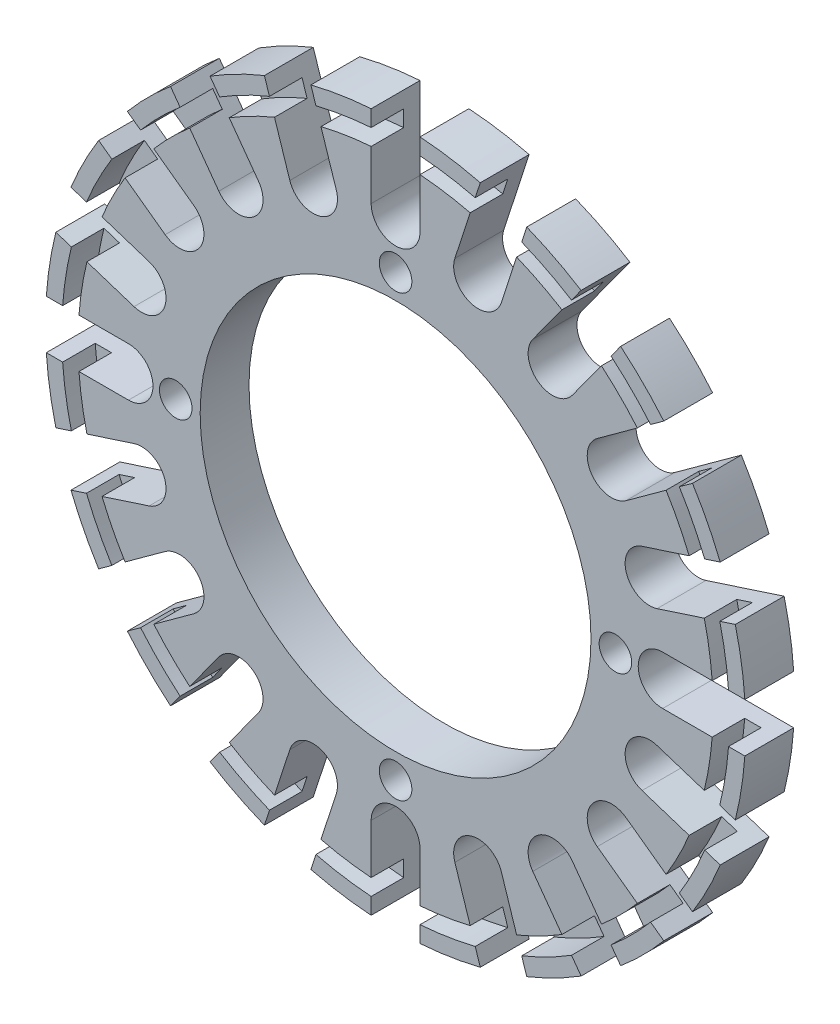
from build123d import *

# Parameters (mm, degrees)
SKETCH1_R           = 12
SKETCH1_R_2         = 1
BOSS_EXTRUDE1_DEPTH = 3
SKETCH2_R           = 20.5
SKETCH2_R_2         = 19.5
CUT_EXTRUDE1_DEPTH  = 2


with BuildPart() as part:
    # Sketch1 → Boss-Extrude1 (new body)
    with BuildSketch(Plane.XY):
        with BuildLine():
            Line((-1.5, 16.4), (-1.5, 21.44761059))
            ThreePointArc((-1.5, 21.44761059), (-3.363340998, 21.235299323), (-5.201091386, 20.861415302))
            Line((-5.201091386, 20.861415302), (-3.641293933, 16.060852359))
            ThreePointArc((-3.641293933, 16.060852359), (-4.604353216, 14.170742093), (-6.494463482, 15.133801376))
            Line((-6.494463482, 15.133801376), (-8.054260935, 19.934364319))
            ThreePointArc((-8.054260935, 19.934364319), (-9.760795744, 19.15664027), (-11.39306371, 18.233159334))
            Line((-11.39306371, 18.233159334), (-8.426152646, 14.149556586))
            ThreePointArc((-8.426152646, 14.149556586), (-8.758000259, 12.054353216), (-10.853203629, 12.386200829))
            Line((-10.853203629, 12.386200829), (-13.820114693, 16.469803577))
            ThreePointArc((-13.820114693, 16.469803577), (-15.202795796, 15.202795796), (-16.469803577, 13.820114693))
            Line((-16.469803577, 13.820114693), (-12.386200829, 10.853203629))
            ThreePointArc((-12.386200829, 10.853203629), (-12.054353216, 8.758000259), (-14.149556586, 8.426152646))
            Line((-14.149556586, 8.426152646), (-18.233159334, 11.39306371))
            ThreePointArc((-18.233159334, 11.39306371), (-19.15664027, 9.760795744), (-19.934364319, 8.054260935))
            Line((-19.934364319, 8.054260935), (-15.133801376, 6.494463482))
            ThreePointArc((-15.133801376, 6.494463482), (-14.170742093, 4.604353216), (-16.060852359, 3.641293933))
            Line((-16.060852359, 3.641293933), (-20.861415302, 5.201091386))
            ThreePointArc((-20.861415302, 5.201091386), (-21.235299323, 3.363340998), (-21.44761059, 1.5))
            Line((-21.44761059, 1.5), (-16.4, 1.5))
            ThreePointArc((-16.4, 1.5), (-14.9, 0), (-16.4, -1.5))
            Line((-16.4, -1.5), (-21.44761059, -1.5))
            ThreePointArc((-21.44761059, -1.5), (-21.235299323, -3.363340998), (-20.861415302, -5.201091386))
            Line((-20.861415302, -5.201091386), (-16.060852359, -3.641293933))
            ThreePointArc((-16.060852359, -3.641293933), (-14.170742093, -4.604353216), (-15.133801376, -6.494463482))
            Line((-15.133801376, -6.494463482), (-19.934364319, -8.054260935))
            ThreePointArc((-19.934364319, -8.054260935), (-19.15664027, -9.760795744), (-18.233159334, -11.39306371))
            Line((-18.233159334, -11.39306371), (-14.149556586, -8.426152646))
            ThreePointArc((-14.149556586, -8.426152646), (-12.054353216, -8.758000259), (-12.386200829, -10.853203629))
            Line((-12.386200829, -10.853203629), (-16.469803577, -13.820114693))
            ThreePointArc((-16.469803577, -13.820114693), (-15.202795796, -15.202795796), (-13.820114693, -16.469803577))
            Line((-13.820114693, -16.469803577), (-10.853203629, -12.386200829))
            ThreePointArc((-10.853203629, -12.386200829), (-8.758000259, -12.054353216), (-8.426152646, -14.149556586))
            Line((-8.426152646, -14.149556586), (-11.39306371, -18.233159334))
            ThreePointArc((-11.39306371, -18.233159334), (-9.760795744, -19.15664027), (-8.054260935, -19.934364319))
            Line((-8.054260935, -19.934364319), (-6.494463482, -15.133801376))
            ThreePointArc((-6.494463482, -15.133801376), (-4.604353216, -14.170742093), (-3.641293933, -16.060852359))
            Line((-3.641293933, -16.060852359), (-5.201091386, -20.861415302))
            ThreePointArc((-5.201091386, -20.861415302), (-3.363340998, -21.235299323), (-1.5, -21.44761059))
            Line((-1.5, -21.44761059), (-1.5, -16.4))
            ThreePointArc((-1.5, -16.4), (0, -14.9), (1.5, -16.4))
            Line((1.5, -16.4), (1.5, -21.44761059))
            ThreePointArc((1.5, -21.44761059), (3.363340998, -21.235299323), (5.201091386, -20.861415302))
            Line((5.201091386, -20.861415302), (3.641293933, -16.060852359))
            ThreePointArc((3.641293933, -16.060852359), (4.604353216, -14.170742093), (6.494463482, -15.133801376))
            Line((6.494463482, -15.133801376), (8.054260935, -19.934364319))
            ThreePointArc((8.054260935, -19.934364319), (9.760795744, -19.15664027), (11.39306371, -18.233159334))
            Line((11.39306371, -18.233159334), (8.426152646, -14.149556586))
            ThreePointArc((8.426152646, -14.149556586), (8.758000259, -12.054353216), (10.853203629, -12.386200829))
            Line((10.853203629, -12.386200829), (13.820114693, -16.469803577))
            ThreePointArc((13.820114693, -16.469803577), (15.202795796, -15.202795796), (16.469803577, -13.820114693))
            Line((16.469803577, -13.820114693), (12.386200829, -10.853203629))
            ThreePointArc((12.386200829, -10.853203629), (12.054353216, -8.758000259), (14.149556586, -8.426152646))
            Line((14.149556586, -8.426152646), (18.233159334, -11.39306371))
            ThreePointArc((18.233159334, -11.39306371), (19.15664027, -9.760795744), (19.934364319, -8.054260935))
            Line((19.934364319, -8.054260935), (15.133801376, -6.494463482))
            ThreePointArc((15.133801376, -6.494463482), (14.170742093, -4.604353216), (16.060852359, -3.641293933))
            Line((16.060852359, -3.641293933), (20.861415302, -5.201091386))
            ThreePointArc((20.861415302, -5.201091386), (21.235299323, -3.363340998), (21.44761059, -1.5))
            Line((21.44761059, -1.5), (16.4, -1.5))
            ThreePointArc((16.4, -1.5), (14.9, 0), (16.4, 1.5))
            Line((16.4, 1.5), (21.44761059, 1.5))
            ThreePointArc((21.44761059, 1.5), (21.235299323, 3.363340998), (20.861415302, 5.201091386))
            Line((20.861415302, 5.201091386), (16.060852359, 3.641293933))
            ThreePointArc((16.060852359, 3.641293933), (14.170742093, 4.604353216), (15.133801376, 6.494463482))
            Line((15.133801376, 6.494463482), (19.934364319, 8.054260935))
            ThreePointArc((19.934364319, 8.054260935), (19.15664027, 9.760795744), (18.233159334, 11.39306371))
            Line((18.233159334, 11.39306371), (14.149556586, 8.426152646))
            ThreePointArc((14.149556586, 8.426152646), (12.054353216, 8.758000259), (12.386200829, 10.853203629))
            Line((12.386200829, 10.853203629), (16.469803577, 13.820114693))
            ThreePointArc((16.469803577, 13.820114693), (15.202795796, 15.202795796), (13.820114693, 16.469803577))
            Line((13.820114693, 16.469803577), (10.853203629, 12.386200829))
            ThreePointArc((10.853203629, 12.386200829), (8.758000259, 12.054353216), (8.426152646, 14.149556586))
            Line((8.426152646, 14.149556586), (11.39306371, 18.233159334))
            ThreePointArc((11.39306371, 18.233159334), (9.760795744, 19.15664027), (8.054260935, 19.934364319))
            Line((8.054260935, 19.934364319), (6.494463482, 15.133801376))
            ThreePointArc((6.494463482, 15.133801376), (4.604353216, 14.170742093), (3.641293933, 16.060852359))
            Line((3.641293933, 16.060852359), (5.201091386, 20.861415302))
            ThreePointArc((5.201091386, 20.861415302), (3.363340998, 21.235299323), (1.5, 21.44761059))
            Line((1.5, 21.44761059), (1.5, 16.4))
            ThreePointArc((1.5, 16.4), (0, 14.9), (-1.5, 16.4))
        make_face()
        Circle(SKETCH1_R, mode=Mode.SUBTRACT)
        with Locations((0, 13.5)):
            Circle(SKETCH1_R_2, mode=Mode.SUBTRACT)
        with Locations((13.5, 0)):
            Circle(SKETCH1_R_2, mode=Mode.SUBTRACT)
        with Locations((0, -13.5)):
            Circle(SKETCH1_R_2, mode=Mode.SUBTRACT)
        with Locations((-13.5, 0)):
            Circle(SKETCH1_R_2, mode=Mode.SUBTRACT)
    extrude(amount=BOSS_EXTRUDE1_DEPTH)

    # Sketch2 → Cut-Extrude1 (cut)
    with BuildSketch(Plane.XY.offset(3)):
        Circle(SKETCH2_R)
        Circle(SKETCH2_R_2, mode=Mode.SUBTRACT)
    extrude(amount=-CUT_EXTRUDE1_DEPTH, mode=Mode.SUBTRACT)


solid = part.part
